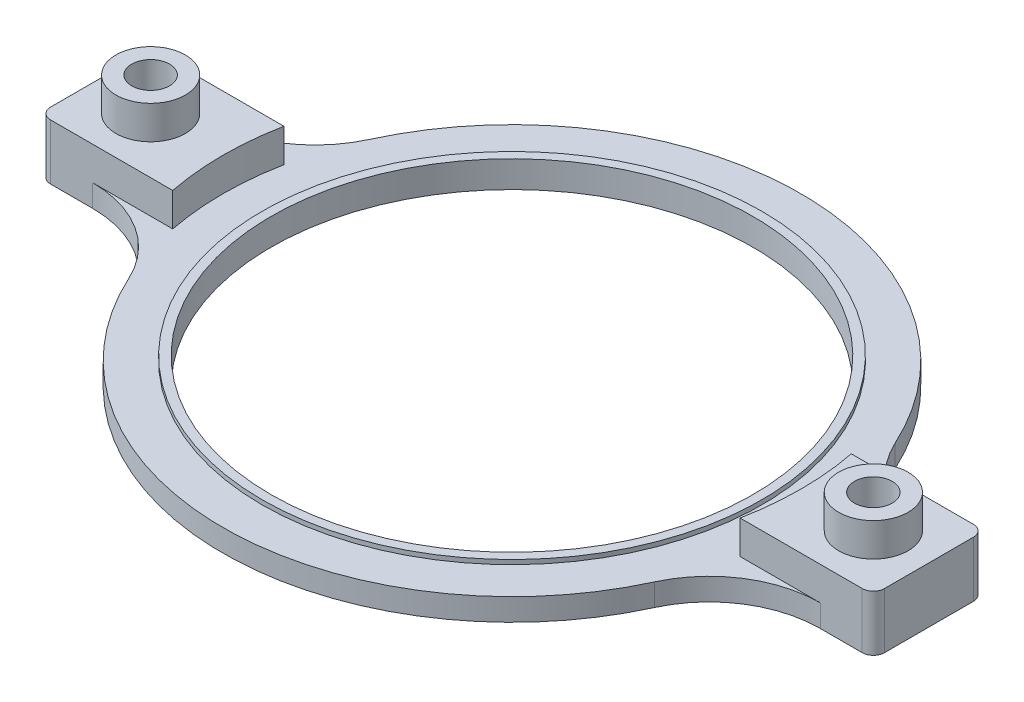
from build123d import *

# Parameters (mm, degrees)
SKETCH1_R            = 26
SKETCH1_R_2          = 21.675
BOSS_EXTRUDE1_DEPTH  = 2
SKETCH2_R            = 22.475
SKETCH2_R_2          = 21.675
BOSS_EXTRUDE2_DEPTH  = 0.4
BOSS_EXTRUDE3_DEPTH  = 5
SKETCH4_W            = 10
SKETCH4_H            = 2
BOSS_EXTRUDE4_DEPTH  = 9.9853
SKETCH5_R            = 3.125
BOSS_EXTRUDE7_DEPTH  = 5
M3_CLEARANCE_HOLE1_D = 3.4
FILLET1_R            = 1
SKETCH9_R            = 1.7
BOSS_EXTRUDE8_DEPTH  = 3
FILLET3_R            = 10


with BuildPart() as part:
    # Sketch1 → Boss-Extrude1 (new body)
    with BuildSketch(Plane(origin=(0, 0, 0), x_dir=(1, 0, 0), z_dir=(0, 1, 0))):
        with Locations(Location((0, 0, 0), (0, 0, 270))):
            Circle(SKETCH1_R)
        with Locations(Location((0, 0, 0), (0, 0, 270))):
            Circle(SKETCH1_R_2, mode=Mode.SUBTRACT)
    extrude(amount=BOSS_EXTRUDE1_DEPTH)

    # Sketch2 → Boss-Extrude2 (add)
    with BuildSketch(Plane(origin=(0, 2, 0), x_dir=(1, 0, 0), z_dir=(0, 1, 0))):
        with Locations(Location((0, 0, 0), (0, 0, 270))):
            Circle(SKETCH2_R)
        with Locations(Location((0, 0, 0), (0, 0, 270))):
            Circle(SKETCH2_R_2, mode=Mode.SUBTRACT)
    extrude(amount=BOSS_EXTRUDE2_DEPTH)

    # Sketch3 → Boss-Extrude3 (add)
    with BuildSketch(Plane.XZ):
        with BuildLine():
            Line((25.514701644, -5), (27.514701644, -5))
            Line((27.514701644, -5), (27.514701644, 5))
            Line((27.514701644, 5), (25.514701644, 5))
            ThreePointArc((25.514701644, 5), (26, 0), (25.514701644, -5))
        make_face()
    boss_extrude3 = extrude(amount=-BOSS_EXTRUDE3_DEPTH)

    # Sketch4 → Boss-Extrude4 (add)
    with BuildSketch(Plane(origin=(27.514701644, 0, 0), x_dir=(0, 0, -1), z_dir=(1, 0, 0))):
        with Locations((0, 4)):
            Rectangle(SKETCH4_W, SKETCH4_H)
    boss_extrude4 = extrude(amount=BOSS_EXTRUDE4_DEPTH)

    # Sketch5 → Boss-Extrude7 (add)
    with BuildSketch(Plane.XZ.offset(-3)):
        with Locations(Location((32.500001644, 0, 0), (0, 0, 270))):
            Circle(SKETCH5_R)
    boss_extrude7 = extrude(amount=-BOSS_EXTRUDE7_DEPTH)

    # M3 Clearance Hole1 (through all)
    with Locations(Plane.XZ.offset(-3)):
        with Locations((32.500001644, 0)):
            m3_clearance_hole1 = Hole(M3_CLEARANCE_HOLE1_D / 2)

    # Mirror1: Boss-Extrude3, Boss-Extrude4, Boss-Extrude7, M3 Clearance Hole1 across plane
    add(boss_extrude3.mirror(Plane(origin=(0, 0, 0), x_dir=(0, 0, 1), z_dir=(1, 0, 0))))
    add(boss_extrude4.mirror(Plane(origin=(0, 0, 0), x_dir=(0, 0, 1), z_dir=(1, 0, 0))))
    add(boss_extrude7.mirror(Plane(origin=(0, 0, 0), x_dir=(0, 0, 1), z_dir=(1, 0, 0))))
    add(m3_clearance_hole1.mirror(Plane(origin=(0, 0, 0), x_dir=(0, 0, 1), z_dir=(1, 0, 0))), mode=Mode.SUBTRACT)

    # Fillet1
    fillet1_edges = [part.edges().sort_by_distance(p)[0] for p in [
        (37.500001644, 4, -5),
        (37.500001644, 4, 5),
        (-37.500001644, 4, -5),
        (-37.500001644, 4, 5),
    ]]
    fillet(fillet1_edges, radius=FILLET1_R)

    # Sketch9 → Boss-Extrude8 (add, through all)
    with BuildSketch(Plane.XZ.offset(-3)):
        with BuildLine():
            Line((-37.500001644, 4), (-37.500001644, -4))
            ThreePointArc((-37.500001644, -4), (-37.207108426, -4.707106781), (-36.500001644, -5))
            Line((-36.500001644, -5), (-27.514701644, -5))
            Line((-27.514701644, -5), (-27.514701644, 5))
            Line((-27.514701644, 5), (-36.500001644, 5))
            ThreePointArc((-36.500001644, 5), (-37.207108426, 4.707106781), (-37.500001644, 4))
        make_face()
        with Locations(Location((-32.500001644, 0, 0), (0, 0, 270))):
            Circle(SKETCH9_R, mode=Mode.SUBTRACT)
        with BuildLine():
            Line((37.500001644, -4), (37.500001644, 4))
            ThreePointArc((37.500001644, 4), (37.207108426, 4.707106781), (36.500001644, 5))
            Line((36.500001644, 5), (27.514701644, 5))
            Line((27.514701644, 5), (27.514701644, -5))
            Line((27.514701644, -5), (36.500001644, -5))
            ThreePointArc((36.500001644, -5), (37.207108426, -4.707106781), (37.500001644, -4))
        make_face()
        with Locations(Location((32.500001644, 0, 0), (0, 0, 270))):
            Circle(SKETCH9_R, mode=Mode.SUBTRACT)
    extrude(amount=BOSS_EXTRUDE8_DEPTH)

    # Fillet3
    fillet3_edges = [part.edges().sort_by_distance(p)[0] for p in [
        (25.514701644, 1, -5),
        (25.514701644, 1, 5),
        (-25.514701644, 1, 5),
        (-25.514701644, 1, -5),
    ]]
    fillet(fillet3_edges, radius=FILLET3_R)


solid = part.part
